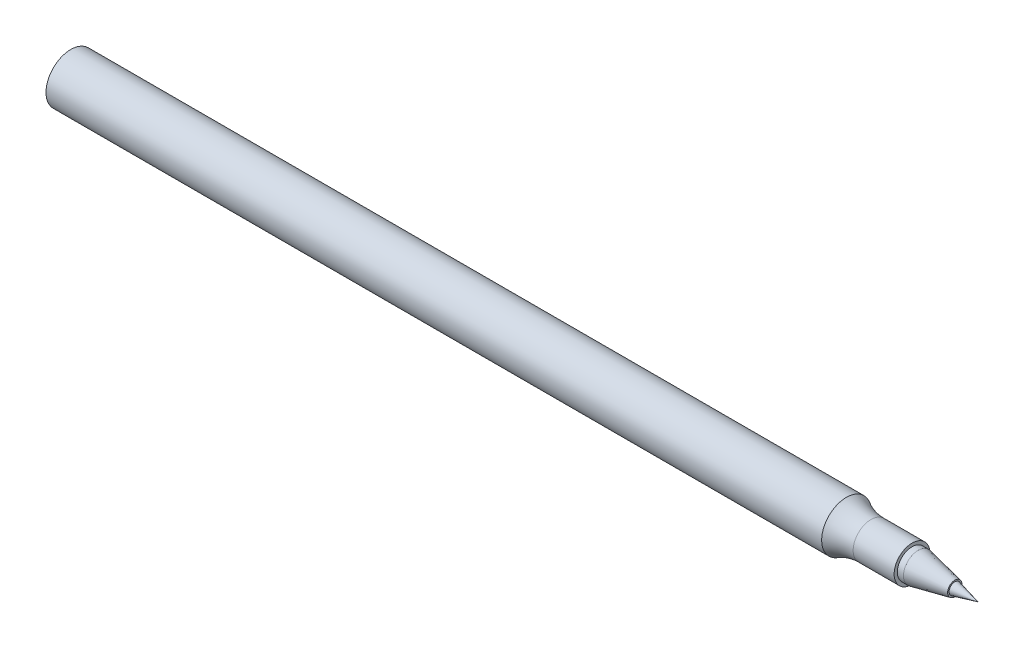
from build123d import *


with BuildPart() as part:
    # Sketch1 → Revolve1 (revolve)
    with BuildSketch(Plane.XY):
        with BuildLine():
            Line((-85.973820479, 0), (-85.973820479, 3.9497))
            Line((-85.973820479, 3.9497), (37.698779521, 3.9497))
            ThreePointArc((37.698779521, 3.9497), (39.589789562, 3.135625716), (41.629711619, 2.8575))
            Line((41.629711619, 2.8575), (48.163579521, 2.8575))
            Line((48.163579521, 2.8575), (48.163579521, 2.3495))
            Line((48.163579521, 2.3495), (49.142936851, 2.3495))
            Line((49.142936851, 2.3495), (54.984769387, 1.145946184))
            Line((54.984769387, 1.145946184), (54.984769387, 0.914360397))
            Line((54.984769387, 0.914360397), (58.679179521, 0))
            Line((58.679179521, 0), (-85.973820479, 0))
        make_face()
    revolve(axis=Axis((-85.973820479, 0, 0), (1, 0, 0)))


solid = part.part
